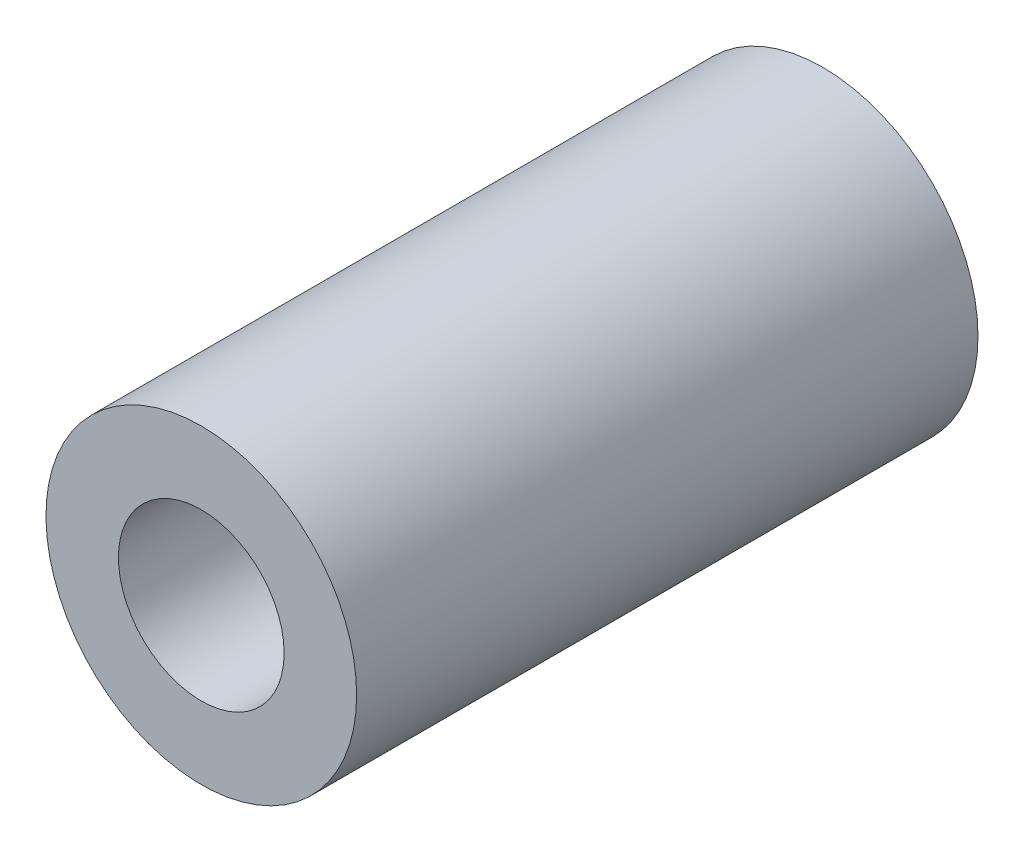
from build123d import *

# Parameters (mm, degrees)
SKETCH2_R           = 2
BOSS_EXTRUDE1_DEPTH = 4
SKETCH3_R           = 2
CUT_EXTRUDE1_DEPTH  = 4
SKETCH4_R           = 3
CUT_EXTRUDE2_DEPTH  = 2
SKETCH5_R           = 3.75
SKETCH5_R_2         = 2
BOSS_EXTRUDE2_DEPTH = 11


with BuildPart() as part:
    # Sketch2 → Boss-Extrude1 (new body)
    with BuildSketch(Plane.XY):
        with BuildLine():
            Line((1.348357032, -93.348542262), (7.005211484, -87.691688216))
            ThreePointArc((7.005211484, -87.691688216), (12.308512224, -87.691688287), (12.308512391, -92.994989027))
            Line((12.308512391, -92.994989027), (6.651658446, -98.651843581))
            ThreePointArc((6.651658446, -98.651843581), (1.348356961, -98.651843747), (1.348357032, -93.348542262))
        make_face()
        with Locations((9.656861819, -90.34333874)):
            Circle(SKETCH2_R, mode=Mode.SUBTRACT)
    extrude(amount=BOSS_EXTRUDE1_DEPTH)

    # Sketch3 → Cut-Extrude1 (cut)
    with BuildSketch(Plane.XY.offset(4)):
        with Locations((4.00000762, -96.00019304)):
            Circle(SKETCH3_R)
    extrude(amount=-CUT_EXTRUDE1_DEPTH, mode=Mode.SUBTRACT)

    # Sketch4 → Cut-Extrude2 (cut)
    with BuildSketch(Plane.XY.offset(4)):
        with Locations((4.00000762, -96.00019304)):
            Circle(SKETCH4_R)
    extrude(amount=-CUT_EXTRUDE2_DEPTH, mode=Mode.SUBTRACT)

    # Sketch5 → Boss-Extrude2 (add)
    with BuildSketch(Plane.XY.offset(4)):
        with Locations((9.656861819, -90.34333874)):
            Circle(SKETCH5_R)
        with Locations((9.656861819, -90.34333874)):
            Circle(SKETCH5_R_2, mode=Mode.SUBTRACT)
    extrude(amount=BOSS_EXTRUDE2_DEPTH)


solid = part.part
